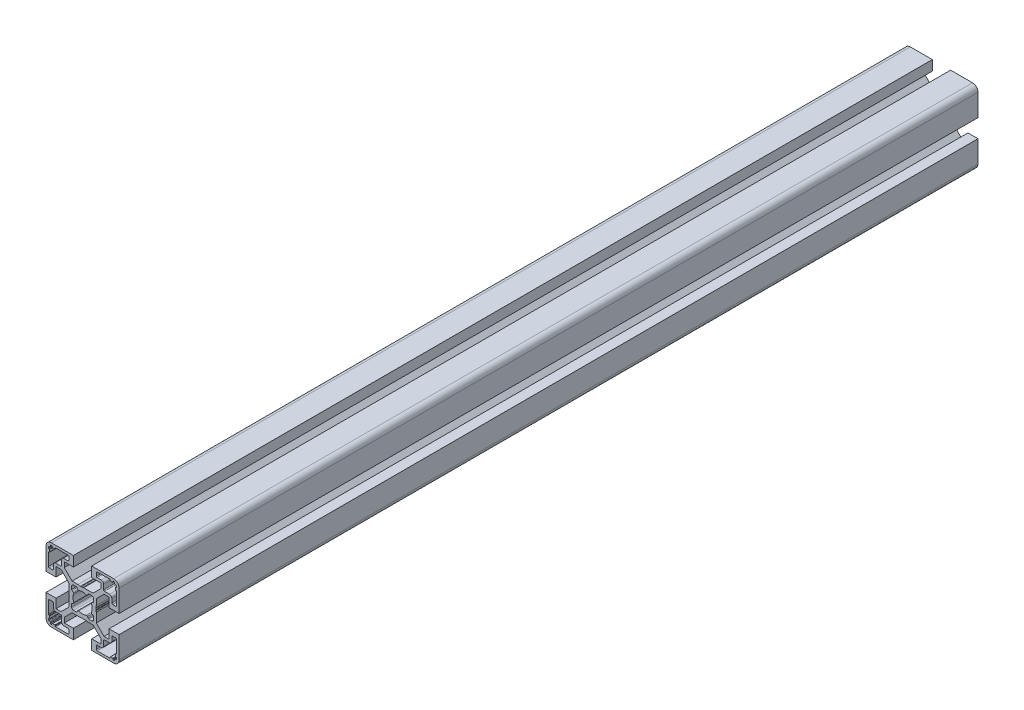
from build123d import *

# Parameters (mm, degrees)
BOSS_EXTRUDE1_DEPTH = 470


with BuildPart() as part:
    # Sketch1 → Boss-Extrude1 (new body)
    with BuildSketch(Plane.XY):
        with BuildLine():
            Line((-11.767766953, -10), (-14.5, -10))
            Line((-14.5, -10), (-14.5, -5))
            Line((-14.5, -5), (-20, -5))
            Line((-20, -5), (-20, -17))
            ThreePointArc((-20, -17), (-19.121320344, -19.121320344), (-17, -20))
            Line((-17, -20), (-5, -20))
            Line((-5, -20), (-5, -14.5))
            Line((-5, -14.5), (-10, -14.5))
            Line((-10, -14.5), (-10, -11.767766953))
            Line((-10, -11.767766953), (-5.732233047, -7.5))
            Line((-5.732233047, -7.5), (-0.653589838, -7.5))
            ThreePointArc((-0.653589838, -7.5), (-0.524180316, -7.482962913), (-0.403589838, -7.433012702))
            Line((-0.403589838, -7.433012702), (0, -7.2))
            Line((0, -7.2), (0.403589838, -7.433012702))
            ThreePointArc((0.403589838, -7.433012702), (0.653589838, -7.5), (0.903589838, -7.433012702))
            Line((0.903589838, -7.433012702), (1.218885629, -7.250976592))
            Line((1.218885629, -7.250976592), (2.5, -7.5))
            Line((2.5, -7.5), (5.732233047, -7.5))
            Line((5.732233047, -7.5), (10, -11.767766953))
            Line((10, -11.767766953), (10, -14.5))
            Line((10, -14.5), (5, -14.5))
            Line((5, -14.5), (5, -20))
            Line((5, -20), (17, -20))
            ThreePointArc((17, -20), (19.121320344, -19.121320344), (20, -17))
            Line((20, -17), (20, -5))
            Line((20, -5), (14.5, -5))
            Line((14.5, -5), (14.5, -10))
            Line((14.5, -10), (11.767766953, -10))
            Line((11.767766953, -10), (7.5, -5.732233047))
            Line((7.5, -5.732233047), (7.5, -0.653589838))
            ThreePointArc((7.5, -0.653589838), (7.482962913, -0.524180316), (7.433012702, -0.403589838))
            Line((7.433012702, -0.403589838), (7.2, 0))
            Line((7.2, 0), (7.433012702, 0.403589838))
            ThreePointArc((7.433012702, 0.403589838), (7.5, 0.653589838), (7.433012702, 0.903589838))
            Line((7.433012702, 0.903589838), (7.250976592, 1.218885629))
            Line((7.250976592, 1.218885629), (7.5, 2.5))
            Line((7.5, 2.5), (7.5, 5.732233047))
            Line((7.5, 5.732233047), (11.767766953, 10))
            Line((11.767766953, 10), (14.5, 10))
            Line((14.5, 10), (14.5, 5))
            Line((14.5, 5), (20, 5))
            Line((20, 5), (20, 17))
            ThreePointArc((20, 17), (19.121320344, 19.121320344), (17, 20))
            Line((17, 20), (5, 20))
            Line((5, 20), (5, 14.5))
            Line((5, 14.5), (10, 14.5))
            Line((10, 14.5), (10, 11.767766953))
            Line((10, 11.767766953), (5.732233047, 7.5))
            Line((5.732233047, 7.5), (0.653589838, 7.5))
            ThreePointArc((0.653589838, 7.5), (0.524180316, 7.482962913), (0.403589838, 7.433012702))
            Line((0.403589838, 7.433012702), (0, 7.2))
            Line((0, 7.2), (-0.403589838, 7.433012702))
            ThreePointArc((-0.403589838, 7.433012702), (-0.653589838, 7.5), (-0.903589838, 7.433012702))
            Line((-0.903589838, 7.433012702), (-1.218885629, 7.250976592))
            Line((-1.218885629, 7.250976592), (-2.5, 7.5))
            Line((-2.5, 7.5), (-5.732233047, 7.5))
            Line((-5.732233047, 7.5), (-10, 11.767766953))
            Line((-10, 11.767766953), (-10, 14.5))
            Line((-10, 14.5), (-5, 14.5))
            Line((-5, 14.5), (-5, 20))
            Line((-5, 20), (-17, 20))
            ThreePointArc((-17, 20), (-19.121320344, 19.121320344), (-20, 17))
            Line((-20, 17), (-20, 5))
            Line((-20, 5), (-14.5, 5))
            Line((-14.5, 5), (-14.5, 10))
            Line((-14.5, 10), (-11.767766953, 10))
            Line((-11.767766953, 10), (-7.5, 5.732233047))
            Line((-7.5, 5.732233047), (-7.5, 0.653589838))
            ThreePointArc((-7.5, 0.653589838), (-7.482962913, 0.524180316), (-7.433012702, 0.403589838))
            Line((-7.433012702, 0.403589838), (-7.2, 0))
            Line((-7.2, 0), (-7.433012702, -0.403589838))
            ThreePointArc((-7.433012702, -0.403589838), (-7.5, -0.653589838), (-7.433012702, -0.903589838))
            Line((-7.433012702, -0.903589838), (-7.250976592, -1.218885629))
            Line((-7.250976592, -1.218885629), (-7.5, -2.5))
            Line((-7.5, -2.5), (-7.5, -5.732233047))
            Line((-7.5, -5.732233047), (-11.767766953, -10))
        make_face()
        with BuildLine():
            Line((7.5, 16.5), (7.5, 18.2))
            ThreePointArc((7.5, 18.2), (7.646446609, 18.553553391), (8, 18.7))
            Line((8, 18.7), (14.8, 18.7))
            ThreePointArc((14.8, 18.7), (14.941421356, 18.641421356), (15, 18.5))
            Line((15, 18.5), (15, 18.2))
            ThreePointArc((15, 18.2), (15.058578644, 18.058578644), (15.2, 18))
            Line((15.2, 18), (16.4, 18))
            ThreePointArc((16.4, 18), (16.541421356, 18.058578644), (16.6, 18.2))
            Line((16.6, 18.2), (16.6, 18.5))
            ThreePointArc((16.6, 18.5), (16.658578644, 18.641421356), (16.8, 18.7))
            Line((16.8, 18.7), (17.3, 18.7))
            ThreePointArc((17.3, 18.7), (17.512132034, 18.612132034), (17.6, 18.4))
            Line((17.6, 18.4), (17.6, 17.9))
            ThreePointArc((17.6, 17.9), (17.687867966, 17.687867966), (17.9, 17.6))
            Line((17.9, 17.6), (18.4, 17.6))
            ThreePointArc((18.4, 17.6), (18.612132034, 17.512132034), (18.7, 17.3))
            Line((18.7, 17.3), (18.7, 16.8))
            ThreePointArc((18.7, 16.8), (18.641421356, 16.658578644), (18.5, 16.6))
            Line((18.5, 16.6), (18.2, 16.6))
            ThreePointArc((18.2, 16.6), (18.058578644, 16.541421356), (18, 16.4))
            Line((18, 16.4), (18, 15.2))
            ThreePointArc((18, 15.2), (18.058578644, 15.058578644), (18.2, 15))
            Line((18.2, 15), (18.5, 15))
            ThreePointArc((18.5, 15), (18.641421356, 14.941421356), (18.7, 14.8))
            Line((18.7, 14.8), (18.7, 8))
            ThreePointArc((18.7, 8), (18.553553391, 7.646446609), (18.2, 7.5))
            Line((18.2, 7.5), (16.5, 7.5))
            ThreePointArc((16.5, 7.5), (16.146446609, 7.646446609), (16, 8))
            Line((16, 8), (16, 10.2))
            ThreePointArc((16, 10.2), (15.619238816, 11.119238816), (14.7, 11.5))
            Line((14.7, 11.5), (12, 11.5))
            ThreePointArc((12, 11.5), (11.646446609, 11.646446609), (11.5, 12))
            Line((11.5, 12), (11.5, 14.7))
            ThreePointArc((11.5, 14.7), (11.119238816, 15.619238816), (10.2, 16))
            Line((10.2, 16), (8, 16))
            ThreePointArc((8, 16), (7.646446609, 16.146446609), (7.5, 16.5))
        make_face(mode=Mode.SUBTRACT)
        with BuildLine():
            Line((14.8, -18.7), (8, -18.7))
            ThreePointArc((8, -18.7), (7.646446609, -18.553553391), (7.5, -18.2))
            Line((7.5, -18.2), (7.5, -16.5))
            ThreePointArc((7.5, -16.5), (7.646446609, -16.146446609), (8, -16))
            Line((8, -16), (10.2, -16))
            ThreePointArc((10.2, -16), (11.119238816, -15.619238816), (11.5, -14.7))
            Line((11.5, -14.7), (11.5, -12))
            ThreePointArc((11.5, -12), (11.646446609, -11.646446609), (12, -11.5))
            Line((12, -11.5), (14.7, -11.5))
            ThreePointArc((14.7, -11.5), (15.619238816, -11.119238816), (16, -10.2))
            Line((16, -10.2), (16, -8))
            ThreePointArc((16, -8), (16.146446609, -7.646446609), (16.5, -7.5))
            Line((16.5, -7.5), (18.2, -7.5))
            ThreePointArc((18.2, -7.5), (18.553553391, -7.646446609), (18.7, -8))
            Line((18.7, -8), (18.7, -14.8))
            ThreePointArc((18.7, -14.8), (18.641421356, -14.941421356), (18.5, -15))
            Line((18.5, -15), (18.2, -15))
            ThreePointArc((18.2, -15), (18.058578644, -15.058578644), (18, -15.2))
            Line((18, -15.2), (18, -16.4))
            ThreePointArc((18, -16.4), (18.058578644, -16.541421356), (18.2, -16.6))
            Line((18.2, -16.6), (18.5, -16.6))
            ThreePointArc((18.5, -16.6), (18.641421356, -16.658578644), (18.7, -16.8))
            Line((18.7, -16.8), (18.7, -17.3))
            ThreePointArc((18.7, -17.3), (18.612132034, -17.512132034), (18.4, -17.6))
            Line((18.4, -17.6), (17.9, -17.6))
            ThreePointArc((17.9, -17.6), (17.687867966, -17.687867966), (17.6, -17.9))
            Line((17.6, -17.9), (17.6, -18.4))
            ThreePointArc((17.6, -18.4), (17.512132034, -18.612132034), (17.3, -18.7))
            Line((17.3, -18.7), (16.8, -18.7))
            ThreePointArc((16.8, -18.7), (16.658578644, -18.641421356), (16.6, -18.5))
            Line((16.6, -18.5), (16.6, -18.2))
            ThreePointArc((16.6, -18.2), (16.541421356, -18.058578644), (16.4, -18))
            Line((16.4, -18), (15.2, -18))
            ThreePointArc((15.2, -18), (15.058578644, -18.058578644), (15, -18.2))
            Line((15, -18.2), (15, -18.5))
            ThreePointArc((15, -18.5), (14.941421356, -18.641421356), (14.8, -18.7))
        make_face(mode=Mode.SUBTRACT)
        with BuildLine():
            Line((-18.7, 16.8), (-18.7, 17.3))
            ThreePointArc((-18.7, 17.3), (-18.612132034, 17.512132034), (-18.4, 17.6))
            Line((-18.4, 17.6), (-17.9, 17.6))
            ThreePointArc((-17.9, 17.6), (-17.687867966, 17.687867966), (-17.6, 17.9))
            Line((-17.6, 17.9), (-17.6, 18.4))
            ThreePointArc((-17.6, 18.4), (-17.512132034, 18.612132034), (-17.3, 18.7))
            Line((-17.3, 18.7), (-16.8, 18.7))
            ThreePointArc((-16.8, 18.7), (-16.658578644, 18.641421356), (-16.6, 18.5))
            Line((-16.6, 18.5), (-16.6, 18.2))
            ThreePointArc((-16.6, 18.2), (-16.541421356, 18.058578644), (-16.4, 18))
            Line((-16.4, 18), (-15.2, 18))
            ThreePointArc((-15.2, 18), (-15.058578644, 18.058578644), (-15, 18.2))
            Line((-15, 18.2), (-15, 18.5))
            ThreePointArc((-15, 18.5), (-14.941421356, 18.641421356), (-14.8, 18.7))
            Line((-14.8, 18.7), (-8, 18.7))
            ThreePointArc((-8, 18.7), (-7.646446609, 18.553553391), (-7.5, 18.2))
            Line((-7.5, 18.2), (-7.5, 16.5))
            ThreePointArc((-7.5, 16.5), (-7.646446609, 16.146446609), (-8, 16))
            Line((-8, 16), (-10.2, 16))
            ThreePointArc((-10.2, 16), (-11.119238816, 15.619238816), (-11.5, 14.7))
            Line((-11.5, 14.7), (-11.5, 12))
            ThreePointArc((-11.5, 12), (-11.646446609, 11.646446609), (-12, 11.5))
            Line((-12, 11.5), (-14.7, 11.5))
            ThreePointArc((-14.7, 11.5), (-15.619238816, 11.119238816), (-16, 10.2))
            Line((-16, 10.2), (-16, 8))
            ThreePointArc((-16, 8), (-16.146446609, 7.646446609), (-16.5, 7.5))
            Line((-16.5, 7.5), (-18.2, 7.5))
            ThreePointArc((-18.2, 7.5), (-18.553553391, 7.646446609), (-18.7, 8))
            Line((-18.7, 8), (-18.7, 14.8))
            ThreePointArc((-18.7, 14.8), (-18.641421356, 14.941421356), (-18.5, 15))
            Line((-18.5, 15), (-18.2, 15))
            ThreePointArc((-18.2, 15), (-18.058578644, 15.058578644), (-18, 15.2))
            Line((-18, 15.2), (-18, 16.4))
            ThreePointArc((-18, 16.4), (-18.058578644, 16.541421356), (-18.2, 16.6))
            Line((-18.2, 16.6), (-18.5, 16.6))
            ThreePointArc((-18.5, 16.6), (-18.641421356, 16.658578644), (-18.7, 16.8))
        make_face(mode=Mode.SUBTRACT)
        with BuildLine():
            Line((-18.7, -14.8), (-18.7, -8))
            ThreePointArc((-18.7, -8), (-18.553553391, -7.646446609), (-18.2, -7.5))
            Line((-18.2, -7.5), (-16.5, -7.5))
            ThreePointArc((-16.5, -7.5), (-16.146446609, -7.646446609), (-16, -8))
            Line((-16, -8), (-16, -10.2))
            ThreePointArc((-16, -10.2), (-15.619238816, -11.119238816), (-14.7, -11.5))
            Line((-14.7, -11.5), (-12, -11.5))
            ThreePointArc((-12, -11.5), (-11.646446609, -11.646446609), (-11.5, -12))
            Line((-11.5, -12), (-11.5, -14.7))
            ThreePointArc((-11.5, -14.7), (-11.119238816, -15.619238816), (-10.2, -16))
            Line((-10.2, -16), (-8, -16))
            ThreePointArc((-8, -16), (-7.646446609, -16.146446609), (-7.5, -16.5))
            Line((-7.5, -16.5), (-7.5, -18.2))
            ThreePointArc((-7.5, -18.2), (-7.646446609, -18.553553391), (-8, -18.7))
            Line((-8, -18.7), (-14.8, -18.7))
            ThreePointArc((-14.8, -18.7), (-14.941421356, -18.641421356), (-15, -18.5))
            Line((-15, -18.5), (-15, -18.2))
            ThreePointArc((-15, -18.2), (-15.058578644, -18.058578644), (-15.2, -18))
            Line((-15.2, -18), (-16.4, -18))
            ThreePointArc((-16.4, -18), (-16.541421356, -18.058578644), (-16.6, -18.2))
            Line((-16.6, -18.2), (-16.6, -18.5))
            ThreePointArc((-16.6, -18.5), (-16.658578644, -18.641421356), (-16.8, -18.7))
            Line((-16.8, -18.7), (-17.3, -18.7))
            ThreePointArc((-17.3, -18.7), (-17.512132034, -18.612132034), (-17.6, -18.4))
            Line((-17.6, -18.4), (-17.6, -17.9))
            ThreePointArc((-17.6, -17.9), (-17.687867966, -17.687867966), (-17.9, -17.6))
            Line((-17.9, -17.6), (-18.4, -17.6))
            ThreePointArc((-18.4, -17.6), (-18.612132034, -17.512132034), (-18.7, -17.3))
            Line((-18.7, -17.3), (-18.7, -16.8))
            ThreePointArc((-18.7, -16.8), (-18.641421356, -16.658578644), (-18.5, -16.6))
            Line((-18.5, -16.6), (-18.2, -16.6))
            ThreePointArc((-18.2, -16.6), (-18.058578644, -16.541421356), (-18, -16.4))
            Line((-18, -16.4), (-18, -15.2))
            ThreePointArc((-18, -15.2), (-18.058578644, -15.058578644), (-18.2, -15))
            Line((-18.2, -15), (-18.5, -15))
            ThreePointArc((-18.5, -15), (-18.641421356, -14.941421356), (-18.7, -14.8))
        make_face(mode=Mode.SUBTRACT)
        with BuildLine():
            Line((-6, 3.490686899), (-6, 5))
            ThreePointArc((-6, 5), (-5.707106781, 5.707106781), (-5, 6))
            Line((-5, 6), (-3.490686899, 6))
            ThreePointArc((-3.490686899, 6), (-3.233167862, 5.92858365), (-3.049213103, 5.734735781))
            Line((-3.049213103, 5.734735781), (-2.689236216, 5.057717724))
            ThreePointArc((-2.689236216, 5.057717724), (-2.414618721, 4.821116073), (-2.052304818, 4.832240157))
            ThreePointArc((-2.052304818, 4.832240157), (0, 5.25), (2.052304818, 4.832240157))
            ThreePointArc((2.052304818, 4.832240157), (2.414618721, 4.821116073), (2.689236216, 5.057717724))
            Line((2.689236216, 5.057717724), (3.049213103, 5.734735781))
            ThreePointArc((3.049213103, 5.734735781), (3.233167862, 5.92858365), (3.490686899, 6))
            Line((3.490686899, 6), (5, 6))
            ThreePointArc((5, 6), (5.707106781, 5.707106781), (6, 5))
            Line((6, 5), (6, 3.490686899))
            ThreePointArc((6, 3.490686899), (5.92858365, 3.233167862), (5.734735781, 3.049213103))
            Line((5.734735781, 3.049213103), (5.057717724, 2.689236216))
            ThreePointArc((5.057717724, 2.689236216), (4.821116073, 2.414618721), (4.832240157, 2.052304818))
            ThreePointArc((4.832240157, 2.052304818), (5.25, 0), (4.832240157, -2.052304818))
            ThreePointArc((4.832240157, -2.052304818), (4.821116073, -2.414618721), (5.057717724, -2.689236216))
            Line((5.057717724, -2.689236216), (5.734735781, -3.049213103))
            ThreePointArc((5.734735781, -3.049213103), (5.92858365, -3.233167862), (6, -3.490686899))
            Line((6, -3.490686899), (6, -5))
            ThreePointArc((6, -5), (5.707106781, -5.707106781), (5, -6))
            Line((5, -6), (3.490686899, -6))
            ThreePointArc((3.490686899, -6), (3.233167862, -5.92858365), (3.049213103, -5.734735781))
            Line((3.049213103, -5.734735781), (2.689236216, -5.057717724))
            ThreePointArc((2.689236216, -5.057717724), (2.414618721, -4.821116073), (2.052304818, -4.832240157))
            ThreePointArc((2.052304818, -4.832240157), (0, -5.25), (-2.052304818, -4.832240157))
            ThreePointArc((-2.052304818, -4.832240157), (-2.414618721, -4.821116073), (-2.689236216, -5.057717724))
            Line((-2.689236216, -5.057717724), (-3.049213103, -5.734735781))
            ThreePointArc((-3.049213103, -5.734735781), (-3.233167862, -5.92858365), (-3.490686899, -6))
            Line((-3.490686899, -6), (-5, -6))
            ThreePointArc((-5, -6), (-5.707106781, -5.707106781), (-6, -5))
            Line((-6, -5), (-6, -3.490686899))
            ThreePointArc((-6, -3.490686899), (-5.92858365, -3.233167862), (-5.734735781, -3.049213103))
            Line((-5.734735781, -3.049213103), (-5.057717724, -2.689236216))
            ThreePointArc((-5.057717724, -2.689236216), (-4.821116073, -2.414618721), (-4.832240157, -2.052304818))
            ThreePointArc((-4.832240157, -2.052304818), (-5.25, 0), (-4.832240157, 2.052304818))
            ThreePointArc((-4.832240157, 2.052304818), (-4.821116073, 2.414618721), (-5.057717724, 2.689236216))
            Line((-5.057717724, 2.689236216), (-5.734735781, 3.049213103))
            ThreePointArc((-5.734735781, 3.049213103), (-5.92858365, 3.233167862), (-6, 3.490686899))
        make_face(mode=Mode.SUBTRACT)
    extrude(amount=-BOSS_EXTRUDE1_DEPTH)


solid = part.part
